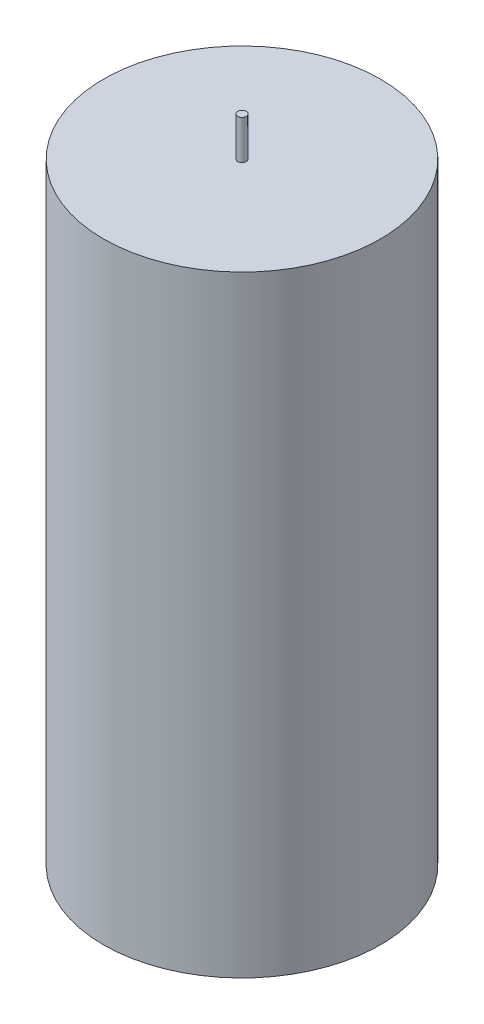
from build123d import *


with BuildPart() as part:
    # Croquis1 → Revolución1 (revolve)
    with BuildSketch(Plane.XY):
        Polygon((2.5, 199.2), (0, 199.2), (0, 0), (80, 0), (80, 176.605), (2.5, 176.605), align=None)
        Polygon((80, 0), (0, 0), (0, -199.2), (2.5, -199.2), (2.5, -176.605), (80, -176.605), align=None)
    revolve(axis=Axis((0, 415.25313391, 0), (0, -1, 0)))


solid = part.part
